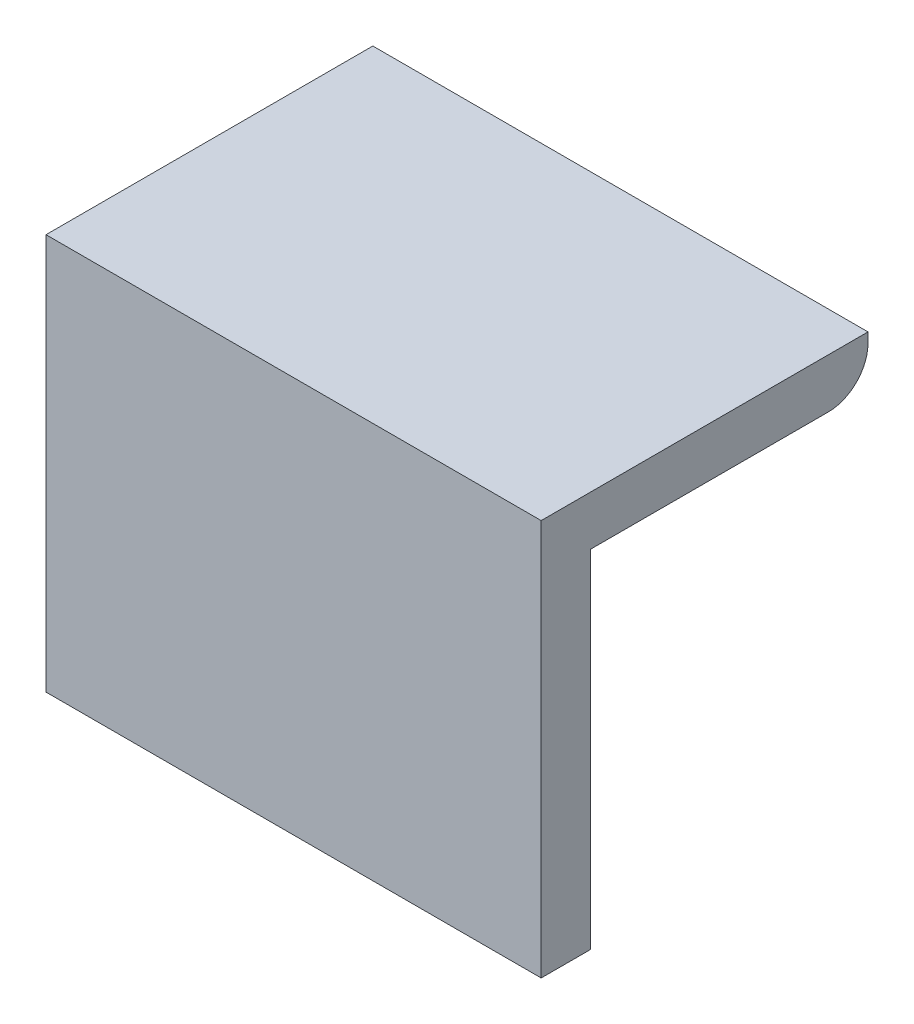
from build123d import *

# Parameters (mm, degrees)
SKETCH1_W           = 50
SKETCH1_H           = 40
BOSS_EXTRUDE1_DEPTH = 5
SKETCH2_W           = 50
SKETCH2_H           = 5
BOSS_EXTRUDE2_DEPTH = 28
FILLET1_R           = 4


with BuildPart() as part:
    # Sketch1 → Boss-Extrude1 (new body)
    with BuildSketch(Plane.XY):
        Rectangle(SKETCH1_W, SKETCH1_H)
    extrude(amount=BOSS_EXTRUDE1_DEPTH)

    # Sketch2 → Boss-Extrude2 (add)
    with BuildSketch(Plane(origin=(0, 0, 0), x_dir=(-1, 0, 0), z_dir=(0, 0, -1))):
        with Locations((0, 17.5)):
            Rectangle(SKETCH2_W, SKETCH2_H)
    extrude(amount=BOSS_EXTRUDE2_DEPTH)

    # Fillet1
    fillet1_edges = [part.edges().sort_by_distance(p)[0] for p in [
        (0, 15, -28),
    ]]
    fillet(fillet1_edges, radius=FILLET1_R)


solid = part.part
